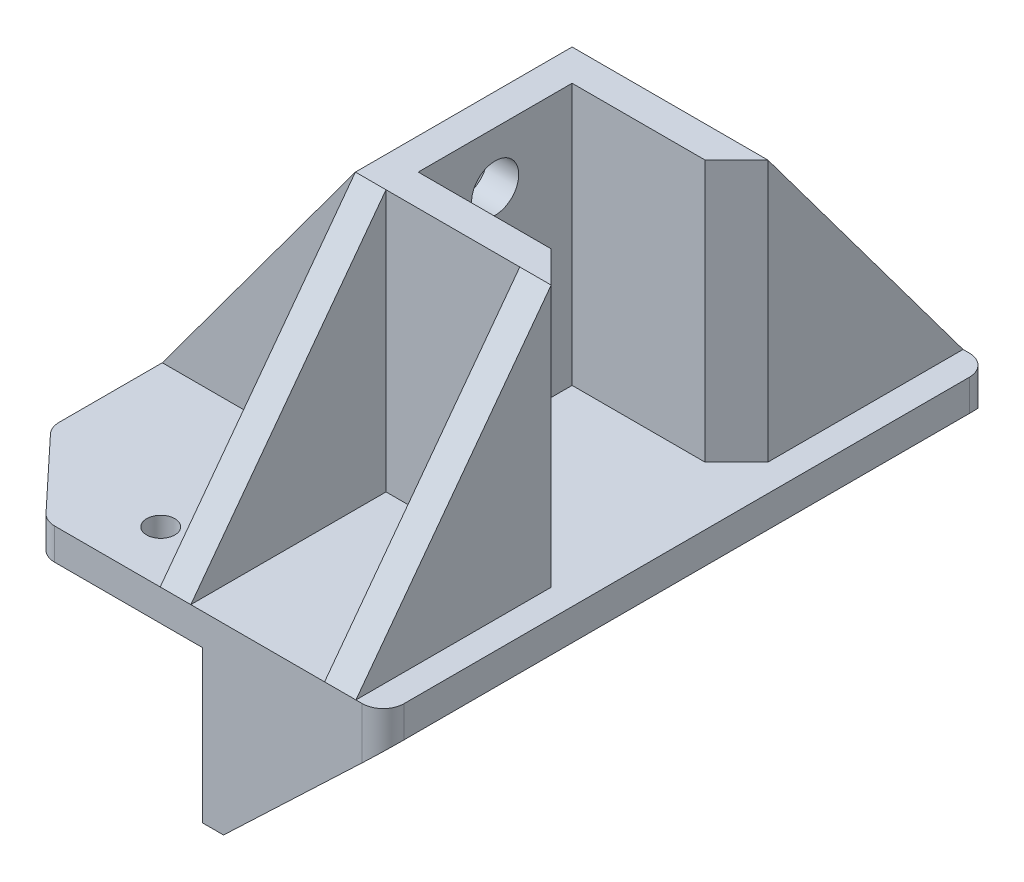
from build123d import *

# Parameters (mm, degrees)
SKETCH1_W           = 36.75
SKETCH1_H           = 58
BOSS_EXTRUDE1_DEPTH = 3
SKETCH2_W           = 2
SKETCH2_H           = 10
BOSS_EXTRUDE2_DEPTH = 14.5
SKETCH3_R           = 1.35
CUT_EXTRUDE1_DEPTH  = 2
BOSS_EXTRUDE3_DEPTH = 25
SKETCH5_R           = 2.25
CUT_EXTRUDE2_DEPTH  = 3
SKETCH6_W           = 58
SKETCH6_H           = 3
BOSS_EXTRUDE4_DEPTH = 3
SKETCH7_R           = 6
CUT_EXTRUDE3_DEPTH  = 3
CUT_EXTRUDE4_DEPTH  = 3
SKETCH9_W           = 2
SKETCH9_H           = 14.5
BOSS_EXTRUDE5_DEPTH = 15.25
CUT_EXTRUDE5_DEPTH  = 80
SKETCH11_R          = 1.35
CUT_EXTRUDE6_DEPTH  = 3
FILLET1_R           = 2
SKETCH12_W          = 2.925
SKETCH12_H          = 18.65
SKETCH12_W_2        = 2.997200628
BOSS_EXTRUDE6_DEPTH = 25
CUT_EXTRUDE7_DEPTH  = 18.7
SKETCH14_W          = 18.45
SKETCH14_H          = 4
BOSS_EXTRUDE7_DEPTH = 25
CUT_EXTRUDE8_DEPTH  = 20.7


with BuildPart() as part:
    # Sketch1 → Boss-Extrude1 (new body)
    with BuildSketch(Plane(origin=(0, 0, 0), x_dir=(1, 0, 0), z_dir=(0, 1, 0))):
        Rectangle(SKETCH1_W, SKETCH1_H)
    extrude(amount=BOSS_EXTRUDE1_DEPTH)

    # Sketch2 → Boss-Extrude2 (add)
    with BuildSketch(Plane.XZ):
        with Locations((2.125, 24)):
            Rectangle(SKETCH2_W, SKETCH2_H)
        with Locations((2.125, -24)):
            Rectangle(SKETCH2_W, SKETCH2_H)
    extrude(amount=BOSS_EXTRUDE2_DEPTH)

    # Sketch3 → Cut-Extrude1 (cut)
    with BuildSketch(Plane(origin=(3.125, 0, 0), x_dir=(0, 0, -1), z_dir=(1, 0, 0))):
        with Locations((-24, -9)):
            Circle(SKETCH3_R)
        with Locations((24, -9)):
            Circle(SKETCH3_R)
    extrude(amount=-CUT_EXTRUDE1_DEPTH, mode=Mode.SUBTRACT)

    # Sketch4 → Boss-Extrude3 (add)
    with BuildSketch(Plane(origin=(0, 3, 0), x_dir=(1, 0, 0), z_dir=(0, 1, 0))):
        Polygon((12.775, 7.35), (0.075, 7.35), (0.075, -7.35), (12.775, -7.35), (15.775, -10.35), (-2.925, -10.35), (-2.925, 10.35), (15.775, 10.35), align=None)
    extrude(amount=BOSS_EXTRUDE3_DEPTH)

    # Sketch5 → Cut-Extrude2 (cut)
    with BuildSketch(Plane.ZY.offset(2.925)):
        with Locations((0, 8)):
            Circle(SKETCH5_R)
        with Locations((0, 23)):
            Circle(SKETCH5_R)
    extrude(amount=-CUT_EXTRUDE2_DEPTH, mode=Mode.SUBTRACT)

    # Sketch6 → Boss-Extrude4 (add)
    with BuildSketch(Plane.ZY.offset(18.375)):
        with Locations((0, 1.5)):
            Rectangle(SKETCH6_W, SKETCH6_H)
    extrude(amount=BOSS_EXTRUDE4_DEPTH)

    # Sketch7 → Cut-Extrude3 (cut)
    with BuildSketch(Plane(origin=(0, 3, 0), x_dir=(1, 0, 0), z_dir=(0, 1, 0))):
        with Locations((-11.375, 0)):
            Circle(SKETCH7_R)
    extrude(amount=-CUT_EXTRUDE3_DEPTH, mode=Mode.SUBTRACT)

    # Sketch8 → Cut-Extrude4 (cut)
    with BuildSketch(Plane(origin=(0, 3, 0), x_dir=(1, 0, 0), z_dir=(0, 1, 0))):
        Polygon((-21.375, 21), (-21.375, -21), (-13.875, -29), (-11.243766746, -32.586617788), (-32.637528156, -32.586617788), (-41.642373039, 35.783998083), (-13.875, 36.078995707), (-13.875, 29), align=None)
    extrude(amount=-CUT_EXTRUDE4_DEPTH, mode=Mode.SUBTRACT)

    # Sketch9 → Boss-Extrude5 (add)
    with BuildSketch(Plane(origin=(3.125, 0, 0), x_dir=(0, 0, -1), z_dir=(1, 0, 0))):
        with Locations((20, -7.25)):
            Rectangle(SKETCH9_W, SKETCH9_H)
        with Locations((28, -7.25)):
            Rectangle(SKETCH9_W, SKETCH9_H)
        with Locations((-28, -7.25)):
            Rectangle(SKETCH9_W, SKETCH9_H)
        with Locations((-20, -7.25)):
            Rectangle(SKETCH9_W, SKETCH9_H)
    extrude(amount=BOSS_EXTRUDE5_DEPTH)

    # Sketch10 → Cut-Extrude5 (cut, symmetric)
    with BuildSketch(Plane(origin=(0, 0, 27), x_dir=(-1, 0, 0), z_dir=(0, 0, -1))):
        Polygon((-18.375, 0), (-3.125, -14.5), (-3.818102744, -23.175648105), (-24.299297104, -22.135397869), (-27.68716384, 0.855740373), align=None)
    extrude(amount=CUT_EXTRUDE5_DEPTH, both=True, mode=Mode.SUBTRACT)

    # Sketch11 → Cut-Extrude6 (cut)
    with BuildSketch(Plane.XZ):
        with Locations((-7.875, 24)):
            Circle(SKETCH11_R)
        with Locations((-7.875, -24)):
            Circle(SKETCH11_R)
    extrude(amount=-CUT_EXTRUDE6_DEPTH, mode=Mode.SUBTRACT)

    # Fillet1
    fillet1_edges = [part.edges().sort_by_distance(p)[0] for p in [
        (-21.375, 1.5, 21),
        (-13.875, 1.5, 29),
        (-21.375, 1.5, -21),
        (-13.875, 1.5, -29),
        (18.375, 1.5, 29),
        (18.375, 1.5, -29),
    ]]
    fillet(fillet1_edges, radius=FILLET1_R)

    # Sketch12 → Boss-Extrude6 (add)
    with BuildSketch(Plane(origin=(0, 3, 0), x_dir=(1, 0, 0), z_dir=(0, 1, 0))):
        with Locations((-1.4625, -19.675)):
            Rectangle(SKETCH12_W, SKETCH12_H)
        with Locations((14.276399686, -19.675)):
            Rectangle(SKETCH12_W_2, SKETCH12_H)
        with Locations((-1.4625, 19.675)):
            Rectangle(SKETCH12_W, SKETCH12_H)
        with Locations((14.276399686, 19.675)):
            Rectangle(SKETCH12_W_2, SKETCH12_H)
    extrude(amount=BOSS_EXTRUDE6_DEPTH)

    # Sketch13 → Cut-Extrude7 (cut)
    with BuildSketch(Plane(origin=(15.775, 0, 0), x_dir=(0, 0, -1), z_dir=(1, 0, 0))):
        Polygon((-10.35, 28), (-29, 3), (-37.617706681, 3), (-37.617706681, 32.391457207), (-10.35, 32.391457207), align=None)
        Polygon((37.617706681, 32.391457207), (10.35, 32.391457207), (10.35, 28), (29, 3), (37.617706681, 3), align=None)
    extrude(amount=-CUT_EXTRUDE7_DEPTH, mode=Mode.SUBTRACT)

    # Sketch14 → Boss-Extrude7 (add)
    with BuildSketch(Plane(origin=(0, 3, 0), x_dir=(1, 0, 0), z_dir=(0, 1, 0))):
        with Locations((-12.15, 8.35)):
            Rectangle(SKETCH14_W, SKETCH14_H)
        with Locations((-12.15, -8.35)):
            Rectangle(SKETCH14_W, SKETCH14_H)
    extrude(amount=BOSS_EXTRUDE7_DEPTH)

    # Sketch15 → Cut-Extrude8 (cut)
    with BuildSketch(Plane.XY.offset(10.35)):
        Polygon((-2.925, 28), (-21.375, 3), (-26.960313264, 3), (-26.960313264, 29.401674183), (-2.925, 29.401674183), align=None)
    extrude(amount=-CUT_EXTRUDE8_DEPTH, mode=Mode.SUBTRACT)


solid = part.part
